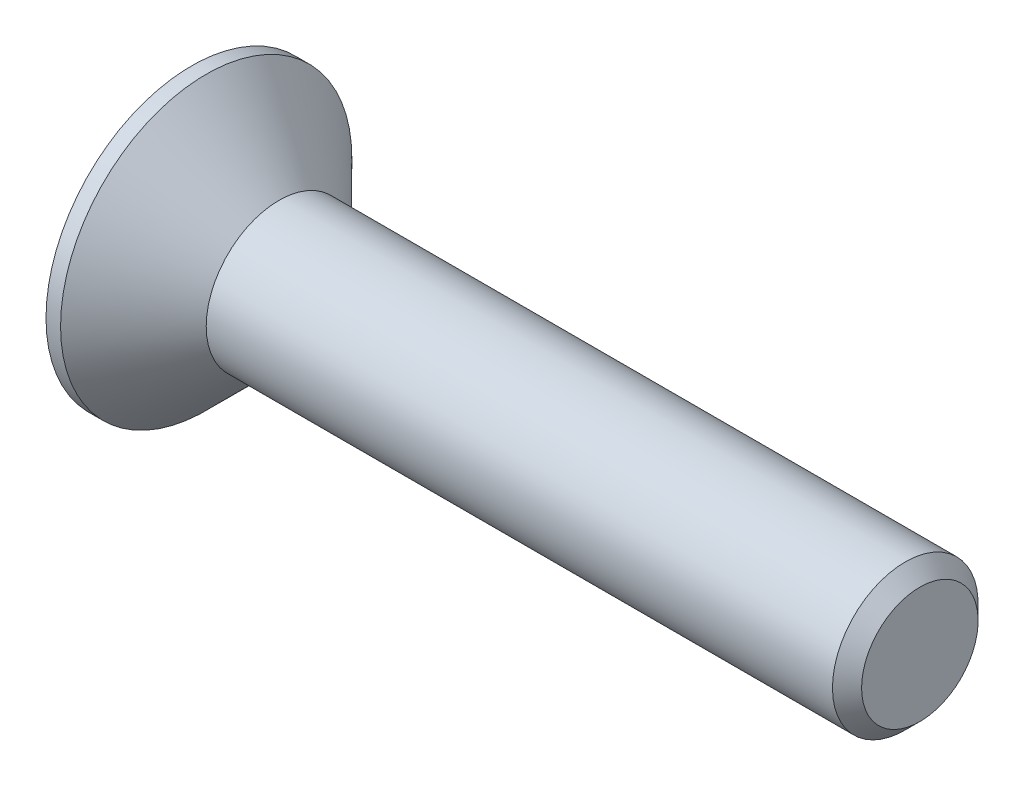
from build123d import *

# Parameters (mm, degrees)
CHAMFER1_SIZE      = 0.2
CUT_EXTRUDE1_DEPTH = 0.75


with BuildPart() as part:
    # Sketch1 → Revolve1 (revolve)
    with BuildSketch(Plane.XY):
        Polygon((0, 1), (-1, 2), (-1.2, 2), (-1.2, 0), (8.8, 0), (8.8, 1), align=None)
    revolve(axis=Axis((-1.2, 0, 0), (1, 0, 0)))

    # Chamfer1
    chamfer1_edges = [part.edges().sort_by_distance(p)[0] for p in [
        (8.8, -1, 0),
    ]]
    chamfer(chamfer1_edges, length=CHAMFER1_SIZE)

    # Sketch2 → Cut-Extrude1 (cut)
    with BuildSketch(Plane.ZY.offset(1.2)):
        Polygon((-0.75055535, 0), (-0.375277675, -0.65), (0.375277675, -0.65), (0.75055535, 0), (0.375277675, 0.65), (-0.375277675, 0.65), align=None)
    extrude(amount=-CUT_EXTRUDE1_DEPTH, mode=Mode.SUBTRACT)


solid = part.part
